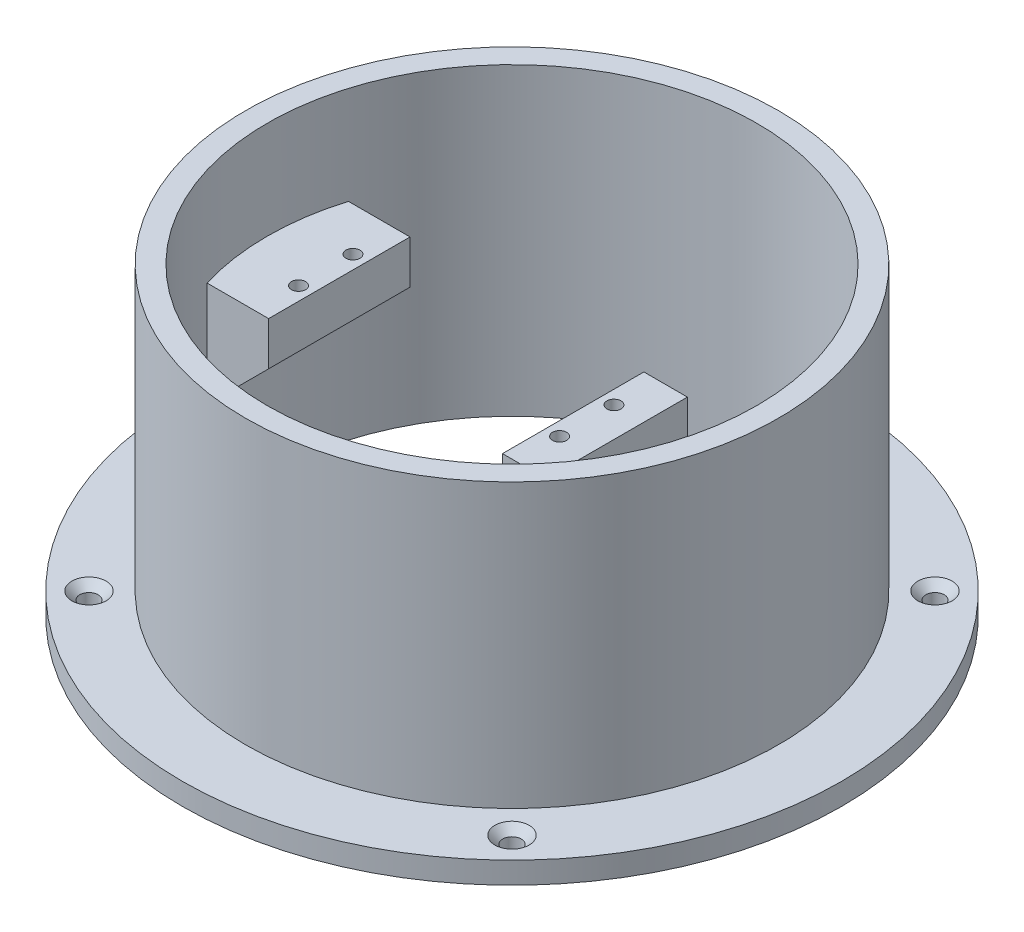
from build123d import *

# Parameters (mm, degrees)
SKETCH1_R                                           = 60.625
SKETCH1_R_2                                         = 45
BOSS_EXTRUDE1_DEPTH                                 = 4
SKETCH2_R                                           = 49
SKETCH2_R_2                                         = 45
BOSS_EXTRUDE2_DEPTH                                 = 52
SKETCH4_W                                           = 13.25
SKETCH4_H                                           = 8
SKETCH4_W_2                                         = 8
SKETCH4_H_2                                         = 38
BOSS_EXTRUDE4_DEPTH                                 = 13
BOSS_EXTRUDE5_DEPTH                                 = 4
SKETCH7_R                                           = 1.3
CUT_EXTRUDE4_DEPTH                                  = 39
SKETCH9_W                                           = 10
SKETCH9_H                                           = 24
CUT_EXTRUDE7_DEPTH                                  = 8
CUT_EXTRUDE9_DEPTH                                  = 5
CSK_FOR_M3_COUNTERSUNK_FLAT_HEAD_SCREW1_D           = 3.4
CSK_FOR_M3_COUNTERSUNK_FLAT_HEAD_SCREW1_DEPTH       = 4
CSK_FOR_M3_COUNTERSUNK_FLAT_HEAD_SCREW1_CSINK_D     = 6.3
CSK_FOR_M3_COUNTERSUNK_FLAT_HEAD_SCREW1_CSINK_ANGLE = 90


with BuildPart() as part:
    # Sketch1 → Boss-Extrude1 (new body)
    with BuildSketch(Plane(origin=(0, 0, 0), x_dir=(1, 0, 0), z_dir=(0, 1, 0))):
        Circle(SKETCH1_R)
        Circle(SKETCH1_R_2, mode=Mode.SUBTRACT)
    extrude(amount=BOSS_EXTRUDE1_DEPTH)

    # Sketch2 → Boss-Extrude2 (add)
    with BuildSketch(Plane(origin=(0, 4, 0), x_dir=(1, 0, 0), z_dir=(0, 1, 0))):
        Circle(SKETCH2_R)
        Circle(SKETCH2_R_2, mode=Mode.SUBTRACT)
    extrude(amount=BOSS_EXTRUDE2_DEPTH)

    # Sketch4 → Boss-Extrude4 (add, symmetric)
    with BuildSketch(Plane.XY):
        with Locations((-38.375, 34)):
            Rectangle(SKETCH4_W, SKETCH4_H)
        Polygon((-31.75, 30), (-45, 30), (-45, 16.75), align=None)
        with Locations((15.25, 19)):
            Rectangle(SKETCH4_W_2, SKETCH4_H_2)
    extrude(amount=BOSS_EXTRUDE4_DEPTH, both=True)

    # Sketch5 → Boss-Extrude5 (add)
    with BuildSketch(Plane.XZ):
        with BuildLine():
            Line((11.25, 13), (29.067400866, 34.352382842))
            ThreePointArc((29.067400866, 34.352382842), (45, 0), (29.067400866, -34.352382842))
            Line((29.067400866, -34.352382842), (11.25, -13))
            Line((11.25, -13), (11.25, 13))
        make_face()
    extrude(amount=-BOSS_EXTRUDE5_DEPTH)

    # Sketch7 → Cut-Extrude4 (cut, through all)
    with BuildSketch(Plane(origin=(0, 38, 0), x_dir=(1, 0, 0), z_dir=(0, 1, 0))):
        with Locations((-34.25, 5)):
            Circle(SKETCH7_R)
        with Locations((-34.25, -5)):
            Circle(SKETCH7_R)
        with Locations((13.75, 5)):
            Circle(SKETCH7_R)
        with Locations((13.75, -5)):
            Circle(SKETCH7_R)
    extrude(amount=-CUT_EXTRUDE4_DEPTH, mode=Mode.SUBTRACT)

    # Sketch9 → Cut-Extrude7 (cut)
    with BuildSketch(Plane.ZY.offset(-11.25)):
        with Locations((0, 17)):
            Rectangle(SKETCH9_W, SKETCH9_H)
    extrude(amount=-CUT_EXTRUDE7_DEPTH, mode=Mode.SUBTRACT)

    # Sketch12 → Cut-Extrude9 (cut, through all)
    with BuildSketch(Plane(origin=(0, 4, 0), x_dir=(1, 0, 0), z_dir=(0, 1, 0))):
        with BuildLine():
            Line((29.479537487, 22.359715328), (27.25, 19.687836398))
            Line((27.25, 19.687836398), (27.25, -19.687836398))
            Line((27.25, -19.687836398), (29.479537487, -22.359715328))
            ThreePointArc((29.479537487, -22.359715328), (37, 0), (29.479537487, 22.359715328))
        make_face()
        Polygon((27.25, -19.687836398), (27.25, 19.687836398), (24.25, 16.092634774), (24.25, -16.092634774), align=None)
    extrude(amount=-CUT_EXTRUDE9_DEPTH, mode=Mode.SUBTRACT)

    # CSK for M3 Countersunk Flat Head Screw1
    with Locations(Plane(origin=(0, 4, 0), x_dir=(1, 0, 0), z_dir=(0, 1, 0))):
        with Locations((-38.890872965, 38.890872965), (-38.890872965, -38.890872965), (38.890872965, -38.890872965), (38.890872965, 38.890872965)):
            CounterSinkHole(CSK_FOR_M3_COUNTERSUNK_FLAT_HEAD_SCREW1_D / 2, CSK_FOR_M3_COUNTERSUNK_FLAT_HEAD_SCREW1_CSINK_D / 2, depth=CSK_FOR_M3_COUNTERSUNK_FLAT_HEAD_SCREW1_DEPTH, counter_sink_angle=CSK_FOR_M3_COUNTERSUNK_FLAT_HEAD_SCREW1_CSINK_ANGLE)


solid = part.part
